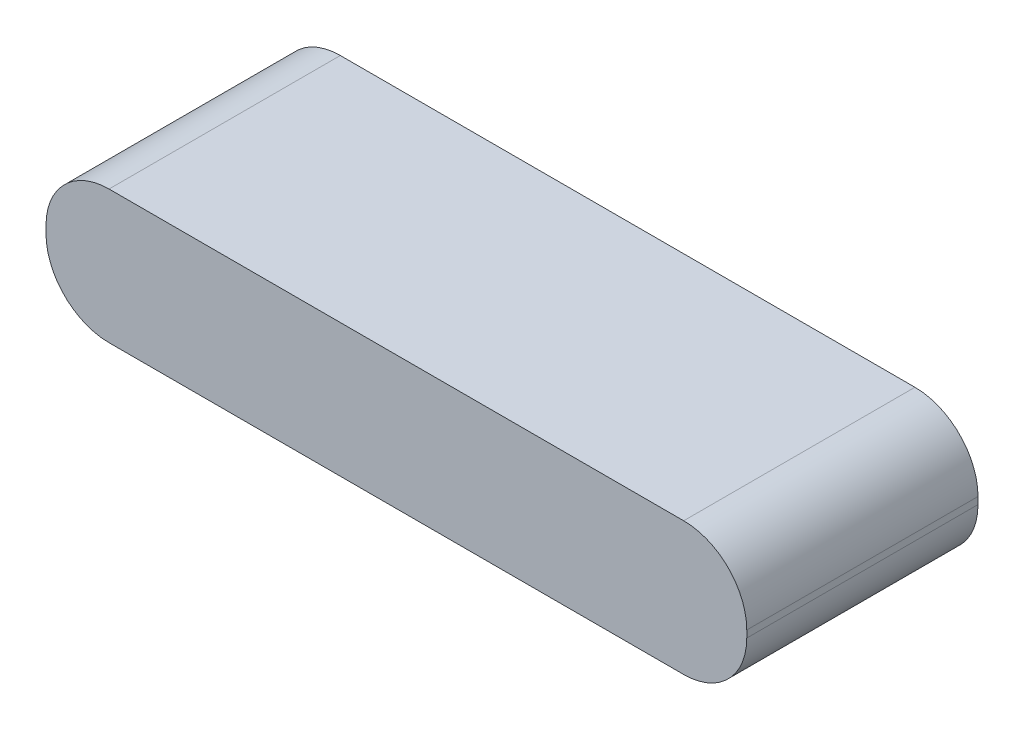
from build123d import *

# Parameters (mm, degrees)
SKETCH1_W           = 100
SKETCH1_H           = 33
BOSS_EXTRUDE1_DEPTH = 19
FILLET1_R           = 9


with BuildPart() as part:
    # Sketch1 → Boss-Extrude1 (new body)
    with BuildSketch(Plane(origin=(0, 0, 0), x_dir=(1, 0, 0), z_dir=(0, 1, 0))):
        Rectangle(SKETCH1_W, SKETCH1_H)
    extrude(amount=BOSS_EXTRUDE1_DEPTH)

    # Fillet1
    fillet1_edges = [part.edges().sort_by_distance(p)[0] for p in [
        (-50, 19, 0),
        (50, 19, 0),
        (-50, 0, 0),
        (50, 0, 0),
    ]]
    fillet(fillet1_edges, radius=FILLET1_R)


solid = part.part
